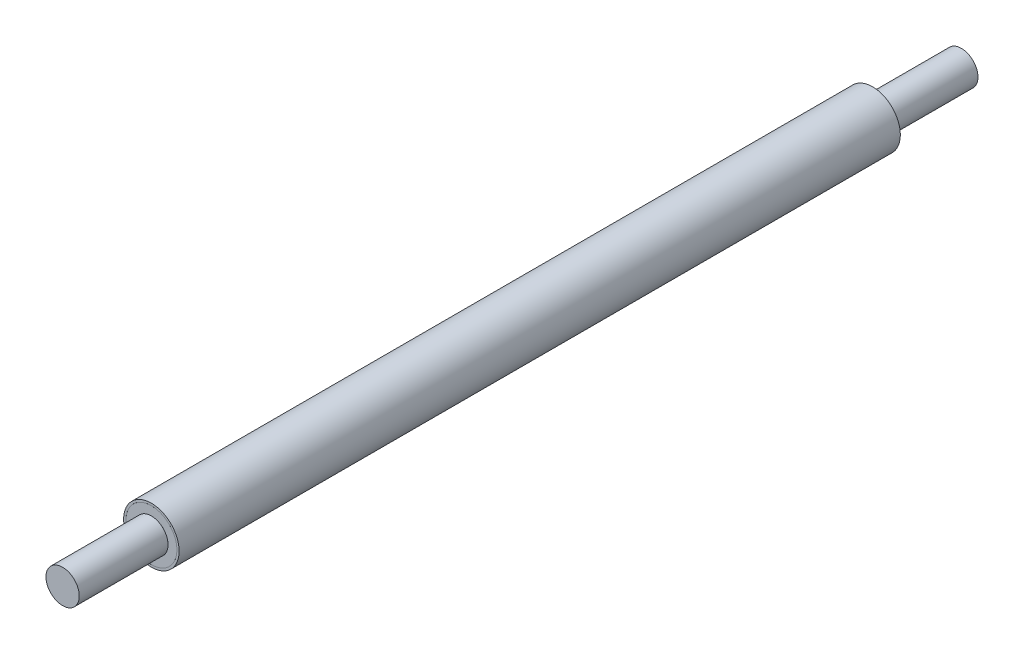
from build123d import *

# Parameters (mm, degrees)
SKETCH1_R           = 25
BOSS_EXTRUDE1_DEPTH = 325
SKETCH2_R           = 15
BOSS_EXTRUDE2_DEPTH = 80
SHELL1_T            = -2
SKETCH3_R           = 23
SKETCH3_R_2         = 15
BOSS_EXTRUDE3_DEPTH = 10


with BuildPart() as part:
    # Sketch1 → Boss-Extrude1 (new, symmetric)
    with BuildSketch(Plane.XY):
        Circle(SKETCH1_R)
    extrude(amount=BOSS_EXTRUDE1_DEPTH, both=True)

    # Shell1
    shell1_openings = [part.faces().sort_by_distance(p)[0] for p in [
        (0, 0, 325),
        (0, 0, -325),
    ]]
    offset(amount=SHELL1_T, openings=shell1_openings, kind=Kind.INTERSECTION)


with BuildPart() as body_2:
    # Sketch2 → Boss-Extrude2 (new body)
    with BuildSketch(Plane.XY.offset(325)):
        Circle(SKETCH2_R)
    extrude(amount=BOSS_EXTRUDE2_DEPTH)


with BuildPart() as body_3:
    # Mirror1: mirrored copy
    add(body_2.part.mirror(Plane.XY))


with BuildPart() as body_4:
    # Sketch3 → Boss-Extrude3 (new body)
    with BuildSketch(Plane(origin=(0, 0, -325), x_dir=(-1, 0, 0), z_dir=(0, 0, -1))):
        Circle(SKETCH3_R)
        Circle(SKETCH3_R_2, mode=Mode.SUBTRACT)
    extrude(amount=-BOSS_EXTRUDE3_DEPTH)


with BuildPart() as body_5:
    # Mirror2: mirrored copy
    add(body_4.part.mirror(Plane.XY))


solid = Compound([part.part, body_2.part, body_3.part, body_4.part, body_5.part])
